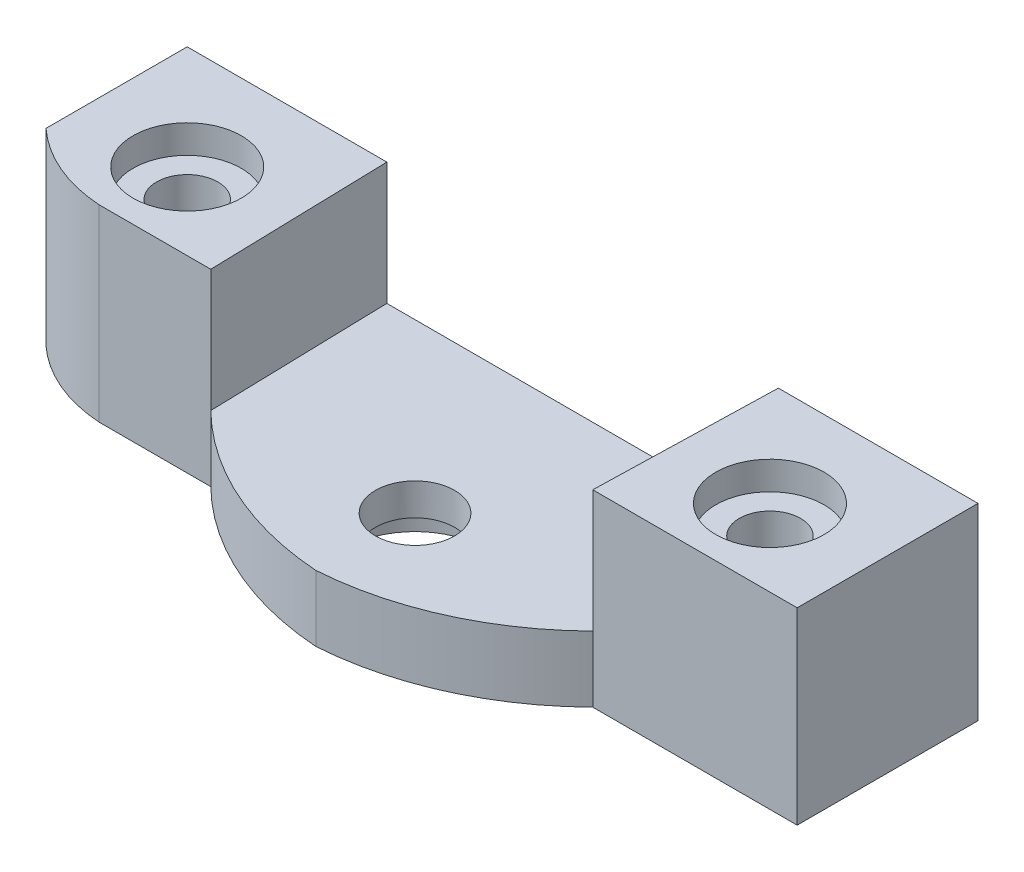
from build123d import *

# Parameters (mm, degrees)
SKETCH1_W           = 42
SKETCH1_H           = 10
SKETCH1_R           = 1.625
BOSS_EXTRUDE1_DEPTH = 10
SKETCH2_R           = 10.152178523
CUT_EXTRUDE2_DEPTH  = 6.5
CUT_EXTRUDE3_DEPTH  = 10
SKETCH4_R           = 2.875
CUT_EXTRUDE4_DEPTH  = 1.5
CUT_EXTRUDE5_DEPTH  = 8
BOSS_EXTRUDE6_DEPTH = 3.5
SKETCH10_R          = 2.1
CUT_EXTRUDE6_DEPTH  = 4.5
CUT_EXTRUDE8_DEPTH  = 10
SKETCH13_R          = 3.75
CUT_EXTRUDE9_DEPTH  = 1.8


with BuildPart() as part:
    # Sketch1 → Boss-Extrude1 (new body)
    with BuildSketch(Plane(origin=(0, 0, 0), x_dir=(1, 0, 0), z_dir=(0, 1, 0))):
        Rectangle(SKETCH1_W, SKETCH1_H)
        with Locations((-15.475, -0.525)):
            Circle(SKETCH1_R, mode=Mode.SUBTRACT)
        with Locations((15.475, -0.525)):
            Circle(SKETCH1_R, mode=Mode.SUBTRACT)
    extrude(amount=BOSS_EXTRUDE1_DEPTH)

    # Sketch2 → Cut-Extrude2 (cut)
    with BuildSketch(Plane(origin=(0, 10, 0), x_dir=(1, 0, 0), z_dir=(0, 1, 0))):
        with Locations((0, -5)):
            Circle(SKETCH2_R)
    extrude(amount=-CUT_EXTRUDE2_DEPTH, mode=Mode.SUBTRACT)

    # Sketch3 → Cut-Extrude3 (cut, symmetric)
    with BuildSketch(Plane(origin=(0, 3.5, 0), x_dir=(1, 0, 0), z_dir=(0, 1, 0))):
        Polygon((-21, -5), (21, -5), (21, -4.605153404), (9.605793631, -4.605153404), (9.605793631, -4.916952006), (-9.605793631, -4.916952006), (-9.605793631, -4.605153404), (-21, -4.605153404), (-21, -4.916952006), align=None)
    extrude(amount=CUT_EXTRUDE3_DEPTH, both=True, mode=Mode.SUBTRACT)

    # Sketch4 → Cut-Extrude4 (cut)
    with BuildSketch(Plane(origin=(0, 10, 0), x_dir=(1, 0, 0), z_dir=(0, 1, 0))):
        with Locations((-15.475, -0.525)):
            Circle(SKETCH4_R)
        with Locations((15.475, -0.525)):
            Circle(SKETCH4_R)
    extrude(amount=-CUT_EXTRUDE4_DEPTH, mode=Mode.SUBTRACT)

    # Sketch6 → Cut-Extrude5 (cut)
    with BuildSketch(Plane(origin=(0, 3.5, 0), x_dir=(1, 0, 0), z_dir=(0, 1, 0))):
        with BuildLine():
            Line((-10.144497274, -4.605153404), (-10.396714549, 5))
            Line((-10.396714549, 5), (-1.751207804, 5))
            ThreePointArc((-1.751207804, 5), (-7.644716659, 1.6801973), (-10.144497274, -4.605153404))
        make_face()
        with BuildLine():
            Line((10.144497274, -4.605153404), (10.396714549, 5))
            Line((10.396714549, 5), (1.751207804, 5))
            ThreePointArc((1.751207804, 5), (7.644716659, 1.6801973), (10.144497274, -4.605153404))
        make_face()
    extrude(amount=CUT_EXTRUDE5_DEPTH, mode=Mode.SUBTRACT)

    # Sketch9 → Boss-Extrude6 (add)
    with BuildSketch(Plane(origin=(0, 0, 0), x_dir=(1, 0, 0), z_dir=(0, 1, 0))):
        with BuildLine():
            Line((-10.144497274, -4.605153404), (-9.605793631, -4.605153404))
            Line((-9.605793631, -4.605153404), (-9.605793631, -4.916952006))
            Line((-9.605793631, -4.916952006), (9.605793631, -4.916952006))
            Line((9.605793631, -4.916952006), (9.605793631, -4.605153404))
            Line((9.605793631, -4.605153404), (10.144497274, -4.605153404))
            ThreePointArc((10.144497274, -4.605153404), (5.480668968, -7.794295111), (0, -9.166952006))
            ThreePointArc((0, -9.166952006), (-5.480668968, -7.794295111), (-10.144497274, -4.605153404))
        make_face()
    extrude(amount=BOSS_EXTRUDE6_DEPTH)

    # Sketch10 → Cut-Extrude6 (cut)
    with BuildSketch(Plane(origin=(0, 3.5, 0), x_dir=(1, 0, 0), z_dir=(0, 1, 0))):
        with Locations((0, -3.9)):
            Circle(SKETCH10_R)
    extrude(amount=-CUT_EXTRUDE6_DEPTH, mode=Mode.SUBTRACT)

    # Sketch12 → Cut-Extrude8 (cut)
    with BuildSketch(Plane(origin=(0, 10, 0), x_dir=(1, 0, 0), z_dir=(0, 1, 0))):
        with BuildLine():
            Line((-21, -4.605153404), (-21, -2.499927291))
            ThreePointArc((-21, -2.499927291), (-18.716787092, -3.977228829), (-16.070810572, -4.605153404))
            Line((-16.070810572, -4.605153404), (-21, -4.605153404))
        make_face()
    extrude(amount=-CUT_EXTRUDE8_DEPTH, mode=Mode.SUBTRACT)

    # Sketch13 → Cut-Extrude9 (cut)
    with BuildSketch(Plane.XZ):
        with Locations((0, 3.9)):
            Circle(SKETCH13_R)
    extrude(amount=-CUT_EXTRUDE9_DEPTH, mode=Mode.SUBTRACT)


solid = part.part
